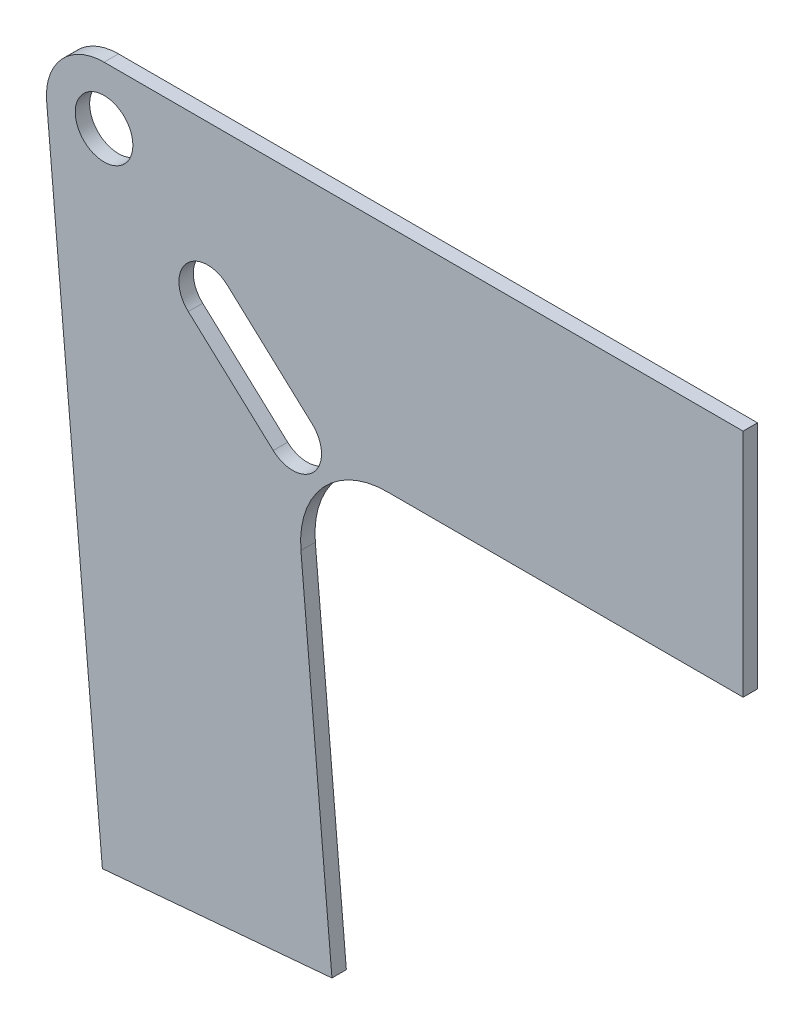
from build123d import *

# Parameters (mm, degrees)
SKETCH1_R           = 6.35
BOSS_EXTRUDE1_DEPTH = 3.175


with BuildPart() as part:
    # Sketch1 → Boss-Extrude1 (new body)
    with BuildSketch(Plane.XY):
        with BuildLine():
            Line((-141.234566003, -128.730482523), (-90.62787534, -124.302970792))
            Line((-90.62787534, -124.302970792), (-97.468846126, -46.110316899))
            ThreePointArc((-97.468846126, -46.110316899), (-92.536470394, -31.580006545), (-78.491337127, -25.4))
            Line((-78.491337127, -25.4), (0, -25.4))
            Line((0, -25.4), (0, 25.4))
            Line((0, 25.4), (-140.859617964, 25.4))
            ThreePointArc((-140.859617964, 25.4), (-150.223040141, 21.279995637), (-153.511290629, 11.593122067))
            Line((-153.511290629, 11.593122067), (-141.234566003, -128.730482523))
        make_face()
        with Locations((-140.859617964, 12.7)):
            Circle(SKETCH1_R, mode=Mode.SUBTRACT)
        with BuildLine():
            Line((-103.570761891, -30.081711089), (-122.297606246, -12.921719815))
            ThreePointArc((-122.297606246, -12.921719815), (-122.689319517, -3.950010908), (-113.717610609, -3.558297638))
            Line((-113.717610609, -3.558297638), (-94.990766254, -20.718288911))
            ThreePointArc((-94.990766254, -20.718288911), (-94.599052984, -29.689997818), (-103.570761891, -30.081711089))
        make_face(mode=Mode.SUBTRACT)
    extrude(amount=BOSS_EXTRUDE1_DEPTH)


solid = part.part
